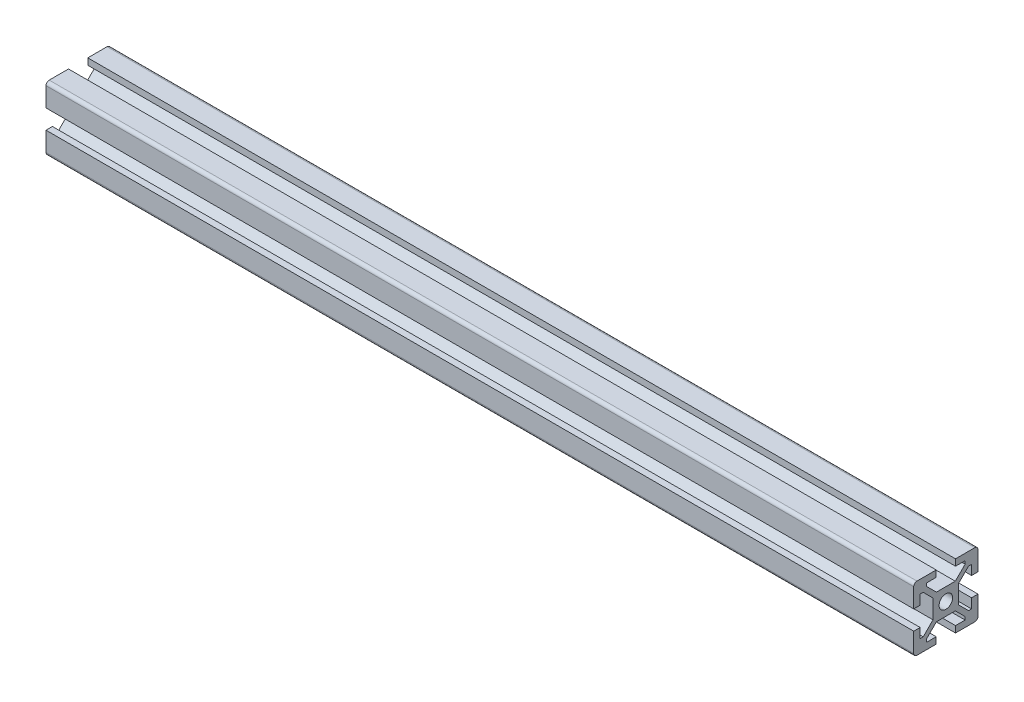
from build123d import *

# Parameters (mm, degrees)
SKETCH1_R           = 2.1
BOSS_EXTRUDE1_DEPTH = 270


with BuildPart() as part:
    # Sketch1 → Boss-Extrude1 (new body)
    with BuildSketch(Plane(origin=(0, 0, 0), x_dir=(0, 0, -1), z_dir=(1, 0, 0))):
        with BuildLine():
            Line((-10, 9), (-10, 3))
            Line((-10, 3), (-8, 3))
            Line((-8, 3), (-8, 6))
            Line((-8, 6), (-7.060660172, 6))
            Line((-7.060660172, 6), (-4, 2.939339828))
            Line((-4, 2.939339828), (-4, -2.939339828))
            Line((-4, -2.939339828), (-7.060660172, -6))
            Line((-7.060660172, -6), (-8, -6))
            Line((-8, -6), (-8, -3))
            Line((-8, -3), (-10, -3))
            Line((-10, -3), (-10, -9))
            ThreePointArc((-10, -9), (-9.707106781, -9.707106781), (-9, -10))
            Line((-9, -10), (-3, -10))
            Line((-3, -10), (-3, -8))
            Line((-3, -8), (-6, -8))
            Line((-6, -8), (-6, -7.060660172))
            Line((-6, -7.060660172), (-2.939339828, -4))
            Line((-2.939339828, -4), (2.939339828, -4))
            Line((2.939339828, -4), (6, -7.060660172))
            Line((6, -7.060660172), (6, -8))
            Line((6, -8), (3, -8))
            Line((3, -8), (3, -10))
            Line((3, -10), (9, -10))
            ThreePointArc((9, -10), (9.707106781, -9.707106781), (10, -9))
            Line((10, -9), (10, -3))
            Line((10, -3), (8, -3))
            Line((8, -3), (8, -6))
            Line((8, -6), (7.060660172, -6))
            Line((7.060660172, -6), (4, -2.939339828))
            Line((4, -2.939339828), (4, 2.939339828))
            Line((4, 2.939339828), (7.060660172, 6))
            Line((7.060660172, 6), (8, 6))
            Line((8, 6), (8, 3))
            Line((8, 3), (10, 3))
            Line((10, 3), (10, 9))
            ThreePointArc((10, 9), (9.707106781, 9.707106781), (9, 10))
            Line((9, 10), (3, 10))
            Line((3, 10), (3, 8))
            Line((3, 8), (6, 8))
            Line((6, 8), (6, 7.060660172))
            Line((6, 7.060660172), (2.939339828, 4))
            Line((2.939339828, 4), (-2.939339828, 4))
            Line((-2.939339828, 4), (-6, 7.060660172))
            Line((-6, 7.060660172), (-6, 8))
            Line((-6, 8), (-3, 8))
            Line((-3, 8), (-3, 10))
            Line((-3, 10), (-9, 10))
            ThreePointArc((-9, 10), (-9.707106781, 9.707106781), (-10, 9))
        make_face()
        Circle(SKETCH1_R, mode=Mode.SUBTRACT)
    extrude(amount=BOSS_EXTRUDE1_DEPTH)


solid = part.part
